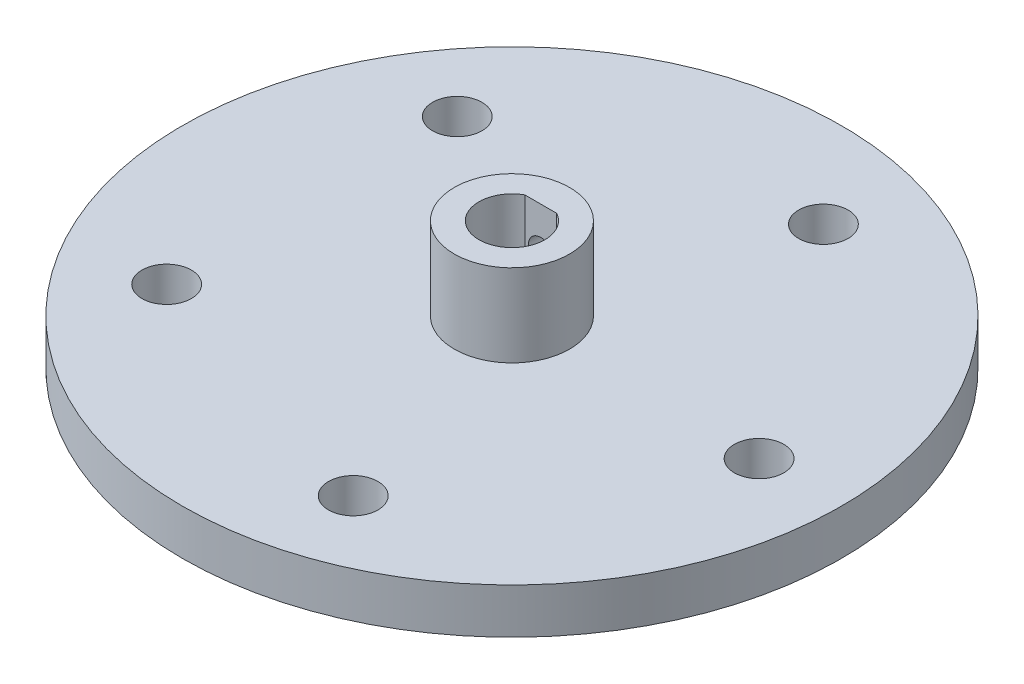
from build123d import *

# Parameters (mm, degrees)
SKETCH1_R           = 40
BOSS_EXTRUDE1_DEPTH = 5.5
SKETCH2_R           = 3
CUT_EXTRUDE1_DEPTH  = 6.5
CIRPATTERN1_COUNT   = 5
SKETCH3_R           = 7
BOSS_EXTRUDE2_DEPTH = 10
CUT_EXTRUDE2_DEPTH  = 20
SKETCH8_R           = 1.5
CUT_EXTRUDE3_DEPTH  = 10


with BuildPart() as part:
    # Sketch1 → Boss-Extrude1 (new body)
    with BuildSketch(Plane(origin=(0, 0, 0), x_dir=(1, 0, 0), z_dir=(0, 1, 0))):
        Circle(SKETCH1_R)
    extrude(amount=BOSS_EXTRUDE1_DEPTH)

    # Sketch2 → Cut-Extrude1 (cut, through all)
    with BuildSketch(Plane(origin=(0, 5.5, 0), x_dir=(1, 0, 0), z_dir=(0, 1, 0))):
        with Locations((30, 0)):
            Circle(SKETCH2_R)
    cut_extrude1 = extrude(amount=-CUT_EXTRUDE1_DEPTH, mode=Mode.SUBTRACT)

    # CirPattern1: Cut-Extrude1 ×5 about axis
    cirpattern1_axis = Axis((0, 0, 0), (0, 1, 0))
    for i in range(1, CIRPATTERN1_COUNT):
        add(cut_extrude1.rotate(cirpattern1_axis, i * 360 / CIRPATTERN1_COUNT), mode=Mode.SUBTRACT)

    # Sketch3 → Boss-Extrude2 (add)
    with BuildSketch(Plane(origin=(0, 5.5, 0), x_dir=(1, 0, 0), z_dir=(0, 1, 0))):
        Circle(SKETCH3_R)
    extrude(amount=BOSS_EXTRUDE2_DEPTH)

    # Sketch7 → Cut-Extrude2 (cut)
    with BuildSketch(Plane(origin=(0, 15.5, 0), x_dir=(1, 0, 0), z_dir=(0, 1, 0))):
        with BuildLine():
            ThreePointArc((4, 0), (3.445719569, 2.031506006), (1.936491673, 3.5))
            Line((1.936491673, 3.5), (-1.936491673, 3.5))
            ThreePointArc((-1.936491673, 3.5), (-2.031506006, -3.445719569), (4, 0))
        make_face()
    extrude(amount=-CUT_EXTRUDE2_DEPTH, mode=Mode.SUBTRACT)

    # Sketch8 → Cut-Extrude3 (cut)
    with BuildSketch(Plane.XY):
        with Locations((0, 10.5)):
            Circle(SKETCH8_R)
    extrude(amount=-CUT_EXTRUDE3_DEPTH, mode=Mode.SUBTRACT)


solid = part.part
